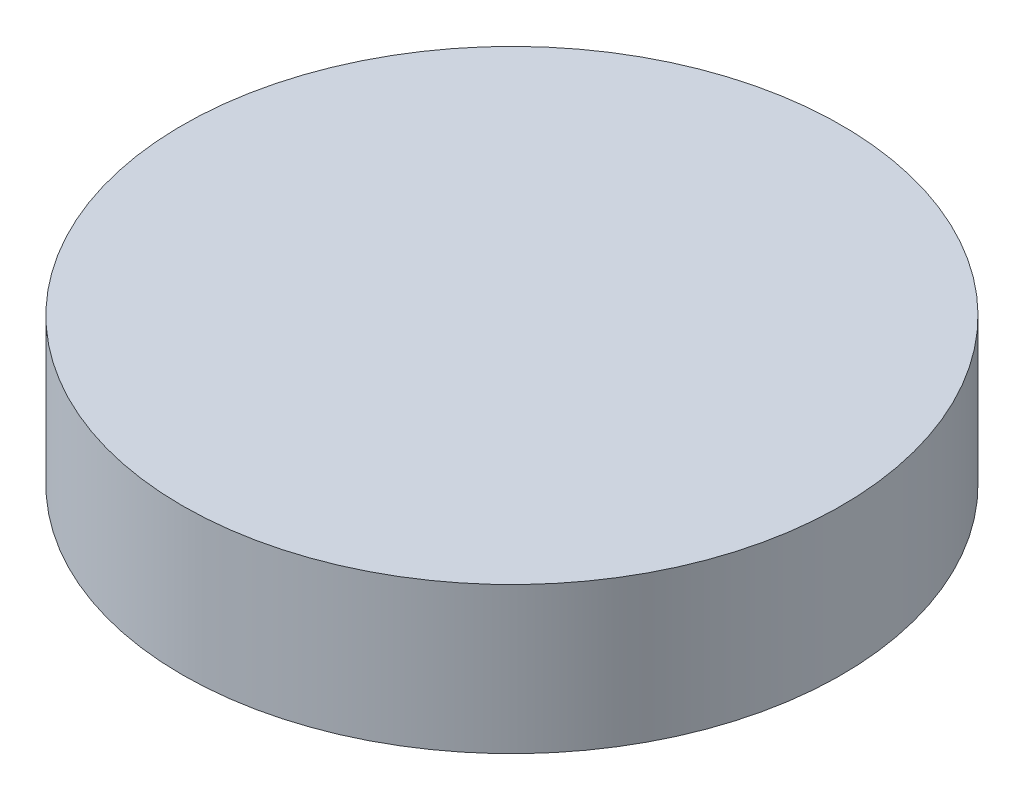
from build123d import *

# Parameters (mm, degrees)
SKETCH1_R           = 45
BOSS_EXTRUDE1_DEPTH = 20


with BuildPart() as part:
    # Sketch1 → Boss-Extrude1 (new body)
    with BuildSketch(Plane(origin=(0, 0, 0), x_dir=(1, 0, 0), z_dir=(0, 1, 0))):
        Circle(SKETCH1_R)
    extrude(amount=BOSS_EXTRUDE1_DEPTH)


solid = part.part
